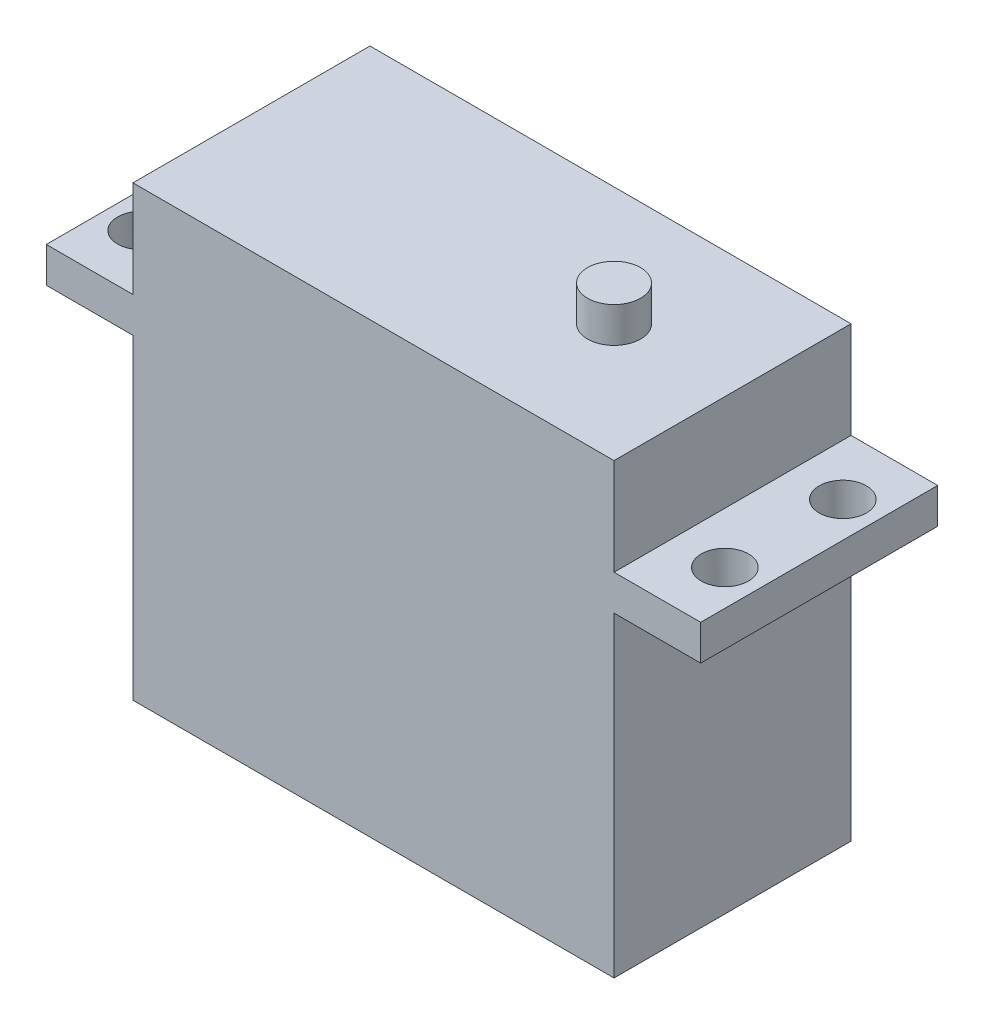
from build123d import *

# Parameters (mm, degrees)
SKETCH1_W           = 40.8
SKETCH1_H           = 38
BOSS_EXTRUDE1_DEPTH = 20.1
SKETCH2_W           = 55.5
SKETCH2_H           = 3
BOSS_EXTRUDE2_DEPTH = 20.1
SKETCH3_R           = 2
CUT_EXTRUDE1_DEPTH  = 30.8
SKETCH4_R           = 2.25
BOSS_EXTRUDE3_DEPTH = 3


with BuildPart() as part:
    # Sketch1 → Boss-Extrude1 (new body)
    with BuildSketch(Plane.XY):
        with Locations((20.4, 19)):
            Rectangle(SKETCH1_W, SKETCH1_H)
    extrude(amount=BOSS_EXTRUDE1_DEPTH)

    # Sketch2 → Boss-Extrude2 (add)
    with BuildSketch(Plane.XY.offset(20.1)):
        with Locations((20.4, 28.3)):
            Rectangle(SKETCH2_W, SKETCH2_H)
    extrude(amount=-BOSS_EXTRUDE2_DEPTH)

    # Sketch3 → Cut-Extrude1 (cut, through all)
    with BuildSketch(Plane(origin=(0, 29.8, 0), x_dir=(1, 0, 0), z_dir=(0, 1, 0))):
        with Locations((-4.35, -5.05)):
            Circle(SKETCH3_R)
        with Locations((-4.35, -15.05)):
            Circle(SKETCH3_R)
        with Locations((45.15, -15.05)):
            Circle(SKETCH3_R)
        with Locations((45.15, -5.05)):
            Circle(SKETCH3_R)
    extrude(amount=-CUT_EXTRUDE1_DEPTH, mode=Mode.SUBTRACT)

    # Sketch4 → Boss-Extrude3 (add)
    with BuildSketch(Plane(origin=(0, 38, 0), x_dir=(1, 0, 0), z_dir=(0, 1, 0))):
        with Locations((30.75, -10.05)):
            Circle(SKETCH4_R)
    extrude(amount=BOSS_EXTRUDE3_DEPTH)


solid = part.part
